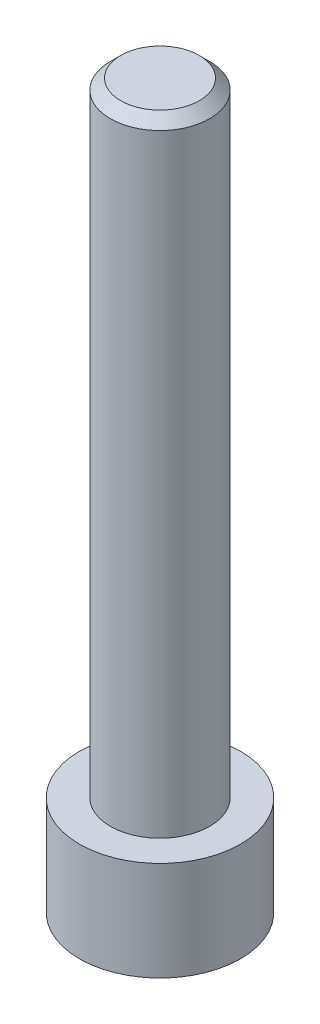
from build123d import *

# Parameters (mm, degrees)
SKETCH1_R           = 3.875
BOSS_EXTRUDE1_DEPTH = 34.78
SKETCH2_OUTSIDE_W   = 17.044
SKETCH2_OUTSIDE_H   = 17.044
SKETCH2_OUTSIDE_R   = 2.39
CUT_EXTRUDE1_DEPTH  = 30
CHAMFER1_SIZE       = 0.5
CUT_EXTRUDE2_DEPTH  = 3.36


with BuildPart() as part:
    # Sketch1 → Boss-Extrude1 (new body)
    with BuildSketch(Plane(origin=(0, 0, 0), x_dir=(1, 0, 0), z_dir=(0, 1, 0))):
        Circle(SKETCH1_R)
    extrude(amount=BOSS_EXTRUDE1_DEPTH)

    # Sketch2 outside → Cut-Extrude1 (cut)
    with BuildSketch(Plane(origin=(0, 34.78, 0), x_dir=(1, 0, 0), z_dir=(0, 1, 0))):
        Rectangle(SKETCH2_OUTSIDE_W, SKETCH2_OUTSIDE_H)
        Circle(SKETCH2_OUTSIDE_R, mode=Mode.SUBTRACT)
    extrude(amount=-CUT_EXTRUDE1_DEPTH, mode=Mode.SUBTRACT)

    # Chamfer1
    chamfer1_edges = [part.edges().sort_by_distance(p)[0] for p in [
        (-2.39, 34.78, 0),
    ]]
    chamfer(chamfer1_edges, length=CHAMFER1_SIZE)

    # Sketch8 → Cut-Extrude2 (cut)
    with BuildSketch(Plane.XZ):
        Polygon((2.644264233, 0), (1.322132116, 2.29), (-1.322132116, 2.29), (-2.644264233, 0), (-1.322132116, -2.29), (1.322132116, -2.29), align=None)
    extrude(amount=-CUT_EXTRUDE2_DEPTH, mode=Mode.SUBTRACT)


solid = part.part
